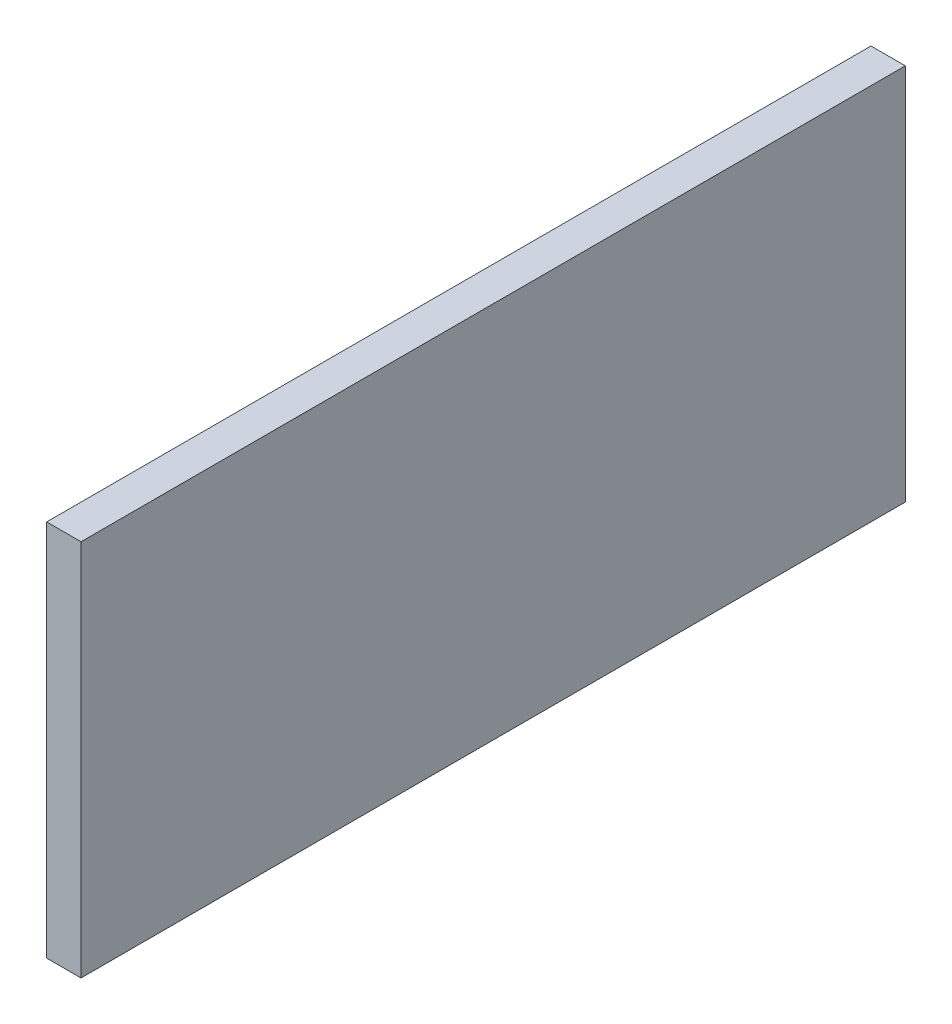
from build123d import *

# Parameters (mm, degrees)
SKETCH1_W           = 304.8
SKETCH1_H           = 139.7
BOSS_EXTRUDE1_DEPTH = 12.7


with BuildPart() as part:
    # Sketch1 → Boss-Extrude1 (new body)
    with BuildSketch(Plane(origin=(0, 0, 0), x_dir=(0, 0, -1), z_dir=(1, 0, 0))):
        Rectangle(SKETCH1_W, SKETCH1_H)
    extrude(amount=BOSS_EXTRUDE1_DEPTH)


solid = part.part
